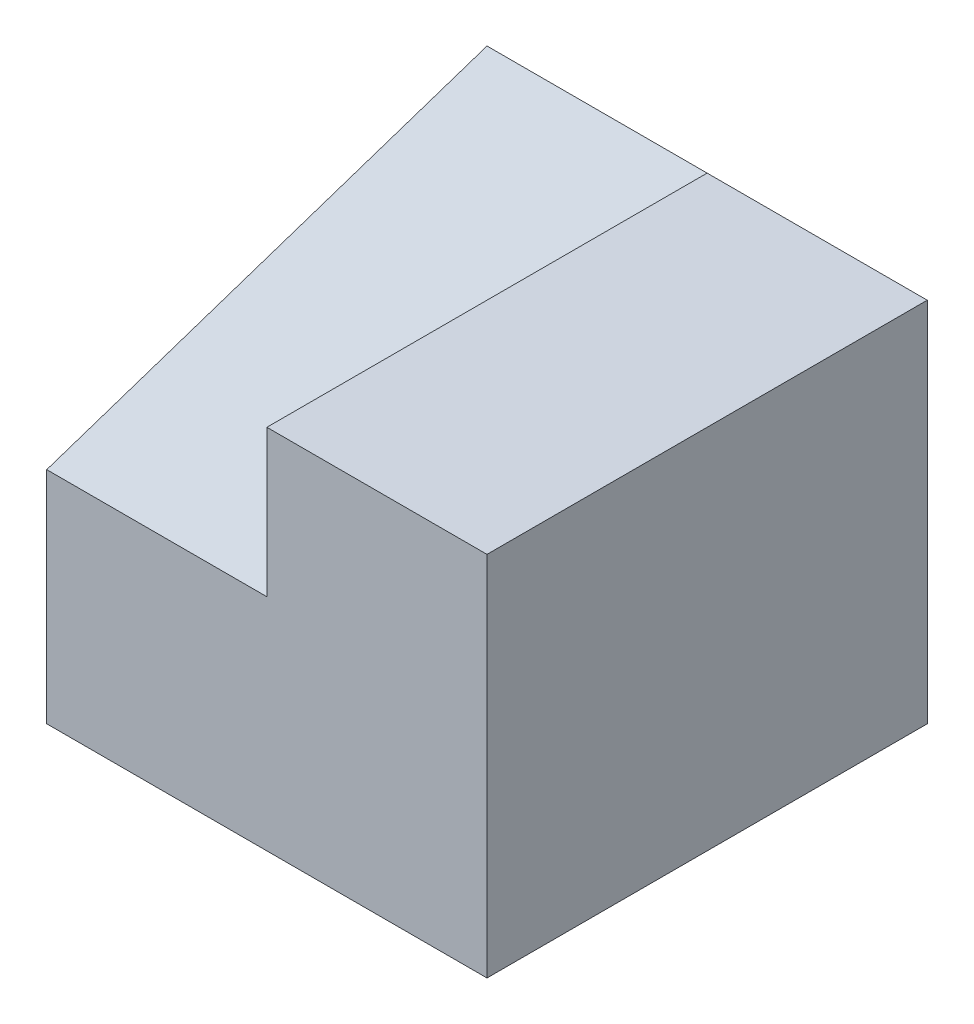
from build123d import *

# Parameters (mm, degrees)
SKETCH3_W           = 6
SKETCH3_H           = 5
BOSS_EXTRUDE6_DEPTH = 6
CUT_EXTRUDE3_DEPTH  = 3


with BuildPart() as part:
    # Sketch3 → Boss-Extrude6 (new body)
    with BuildSketch(Plane.XY):
        with Locations((3, 2.5)):
            Rectangle(SKETCH3_W, SKETCH3_H)
    extrude(amount=BOSS_EXTRUDE6_DEPTH)

    # Sketch7 → Cut-Extrude3 (cut)
    with BuildSketch(Plane.ZY):
        Polygon((0, 5), (6, 3), (6, 5), align=None)
    extrude(amount=-CUT_EXTRUDE3_DEPTH, mode=Mode.SUBTRACT)


solid = part.part
